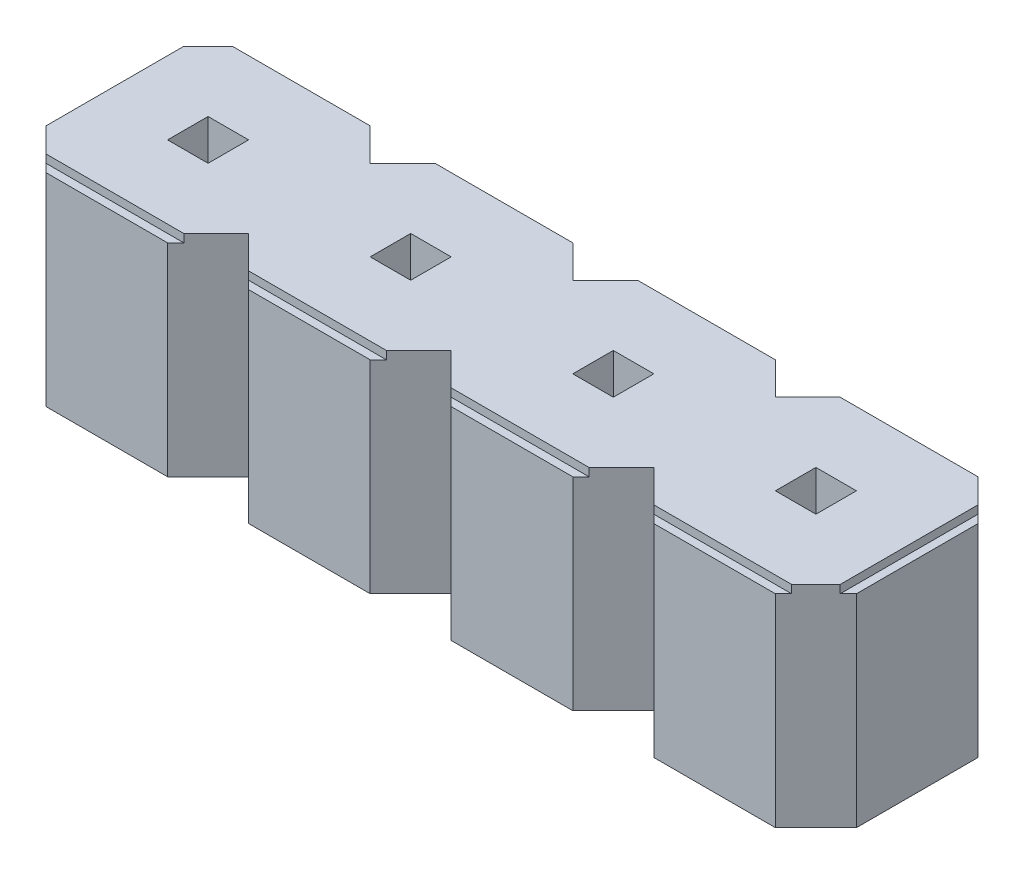
from build123d import *

# Parameters (mm, degrees)
BOSS_EXTRUDE1_DEPTH = 1.3
SKETCH2_W           = 11.59712349
SKETCH2_H           = 4.16940885
SKETCH2_W_2         = 9.8
SKETCH2_H_2         = 2.3
CUT_EXTRUDE1_DEPTH  = 0.1
SKETCH3_W           = 0.5
SKETCH3_H           = 0.5
CUT_EXTRUDE2_DEPTH  = 3.6


with BuildPart() as part:
    # Sketch1 → Boss-Extrude1 (new body, symmetric)
    with BuildSketch(Plane(origin=(0, 0, 0), x_dir=(1, 0, 0), z_dir=(0, 1, 0))):
        Polygon((3.75, -0.75), (6.25, -0.75), (5.75, -1.25), (4.25, -1.25), align=None)
        Polygon((8.25, -1.25), (8.75, -0.75), (6.25, -0.75), (6.75, -1.25), align=None)
        Polygon((8.75, -0.75), (6.25, -0.75), (3.75, -0.75), (3.25, -1.25), (1.75, -1.25), (1.25, -0.75), (-1.25, -0.75), (-1.25, 0.75), (-0.75, 1.25), (0.75, 1.25), (1.25, 0.75), (1.75, 1.25), (3.25, 1.25), (3.75, 0.75), (4.25, 1.25), (5.75, 1.25), (6.25, 0.75), (6.75, 1.25), (8.25, 1.25), (8.75, 0.75), align=None)
        Polygon((-1.25, -0.75), (1.25, -0.75), (0.75, -1.25), (-0.75, -1.25), align=None)
    extrude(amount=BOSS_EXTRUDE1_DEPTH, both=True)

    # Sketch2 → Cut-Extrude1 (cut)
    with BuildSketch(Plane(origin=(0, 1.3, 0), x_dir=(1, 0, 0), z_dir=(0, 1, 0))):
        with Locations((3.75, 0)):
            Rectangle(SKETCH2_W, SKETCH2_H)
        with Locations((3.75, 0)):
            Rectangle(SKETCH2_W_2, SKETCH2_H_2, mode=Mode.SUBTRACT)
    extrude(amount=-CUT_EXTRUDE1_DEPTH, mode=Mode.SUBTRACT)

    # Sketch3 → Cut-Extrude2 (cut, through all)
    with BuildSketch(Plane(origin=(0, 1.3, 0), x_dir=(1, 0, 0), z_dir=(0, 1, 0))):
        with Locations((2.5, 0)):
            Rectangle(SKETCH3_W, SKETCH3_H)
        Rectangle(SKETCH3_W, SKETCH3_H)
        with Locations((5, 0)):
            Rectangle(SKETCH3_W, SKETCH3_H)
        with Locations((7.5, 0)):
            Rectangle(SKETCH3_W, SKETCH3_H)
    extrude(amount=-CUT_EXTRUDE2_DEPTH, mode=Mode.SUBTRACT)


solid = part.part
